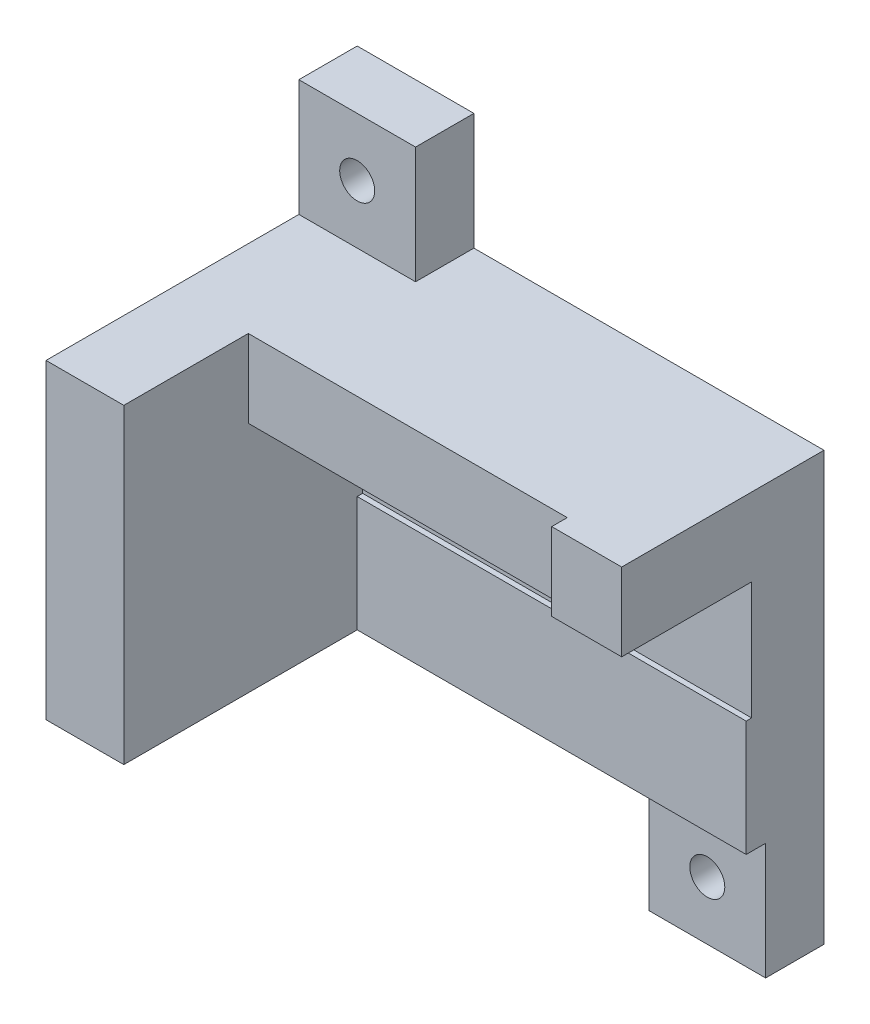
from build123d import *

# Parameters (mm, degrees)
SKETCH1_W           = 60
SKETCH1_H           = 40
BOSS_EXTRUDE1_DEPTH = 40
SKETCH2_W           = 50
SKETCH2_H           = 30
CUT_EXTRUDE1_DEPTH  = 30
SKETCH3_W           = 50
SKETCH3_H           = 15.15
CUT_EXTRUDE2_DEPTH  = 0.7
SKETCH4_W           = 50
SKETCH4_H           = 10
CUT_EXTRUDE3_DEPTH  = 14
SKETCH5_W           = 41
SKETCH5_H           = 10
CUT_EXTRUDE4_DEPTH  = 2
SKETCH6_W           = 15
SKETCH6_H           = 7.5
BOSS_EXTRUDE3_DEPTH = 15
SKETCH7_W           = 15
SKETCH7_H           = 7.5
BOSS_EXTRUDE4_DEPTH = 15
CUT_EXTRUDE5_REACH  = 9.5
SKETCH8_R           = 2.25


with BuildPart() as part:
    # Sketch1 → Boss-Extrude1 (new body)
    with BuildSketch(Plane.XY):
        with Locations((30, 20)):
            Rectangle(SKETCH1_W, SKETCH1_H)
    extrude(amount=BOSS_EXTRUDE1_DEPTH)

    # Sketch2 → Cut-Extrude1 (cut)
    with BuildSketch(Plane.XY.offset(40)):
        with Locations((35, 15)):
            Rectangle(SKETCH2_W, SKETCH2_H)
    extrude(amount=-CUT_EXTRUDE1_DEPTH, mode=Mode.SUBTRACT)

    # Sketch3 → Cut-Extrude2 (cut)
    with BuildSketch(Plane.XY.offset(10)):
        with Locations((35, 22.425)):
            Rectangle(SKETCH3_W, SKETCH3_H)
    extrude(amount=-CUT_EXTRUDE2_DEPTH, mode=Mode.SUBTRACT)

    # Sketch4 → Cut-Extrude3 (cut)
    with BuildSketch(Plane.XY.offset(40)):
        with Locations((35, 35)):
            Rectangle(SKETCH4_W, SKETCH4_H)
    extrude(amount=-CUT_EXTRUDE3_DEPTH, mode=Mode.SUBTRACT)

    # Sketch5 → Cut-Extrude4 (cut)
    with BuildSketch(Plane.XY.offset(26)):
        with Locations((30.5, 35)):
            Rectangle(SKETCH5_W, SKETCH5_H)
    extrude(amount=-CUT_EXTRUDE4_DEPTH, mode=Mode.SUBTRACT)

    # Sketch6 → Boss-Extrude3 (add)
    with BuildSketch(Plane.XZ):
        with Locations((52.5, 3.75)):
            Rectangle(SKETCH6_W, SKETCH6_H)
    extrude(amount=BOSS_EXTRUDE3_DEPTH)

    # Sketch7 → Boss-Extrude4 (add)
    with BuildSketch(Plane(origin=(0, 40, 0), x_dir=(1, 0, 0), z_dir=(0, 1, 0))):
        with Locations((7.5, -3.75)):
            Rectangle(SKETCH7_W, SKETCH7_H)
    extrude(amount=BOSS_EXTRUDE4_DEPTH)

    # Sketch8 → Cut-Extrude5 (cut, up to next)
    with BuildSketch(Plane.XY.offset(7.5), mode=Mode.PRIVATE) as cut_extrude5_sk1:
        with Locations((52.5, -7.5)):
            Circle(SKETCH8_R)
    cut_extrude5_tool1 = extrude(cut_extrude5_sk1.sketch, amount=-CUT_EXTRUDE5_REACH, mode=Mode.PRIVATE) & part.part
    add(cut_extrude5_tool1.solids().sort_by_distance((52.5, -7.5, 7.5))[0], mode=Mode.SUBTRACT)
    # Sketch8 → Cut-Extrude5 (cut, up to next)
    with BuildSketch(Plane.XY.offset(7.5), mode=Mode.PRIVATE) as cut_extrude5_sk2:
        with Locations((7.5, 47.5)):
            Circle(SKETCH8_R)
    cut_extrude5_tool2 = extrude(cut_extrude5_sk2.sketch, amount=-CUT_EXTRUDE5_REACH, mode=Mode.PRIVATE) & part.part
    add(cut_extrude5_tool2.solids().sort_by_distance((7.5, 47.5, 7.5))[0], mode=Mode.SUBTRACT)


solid = part.part
